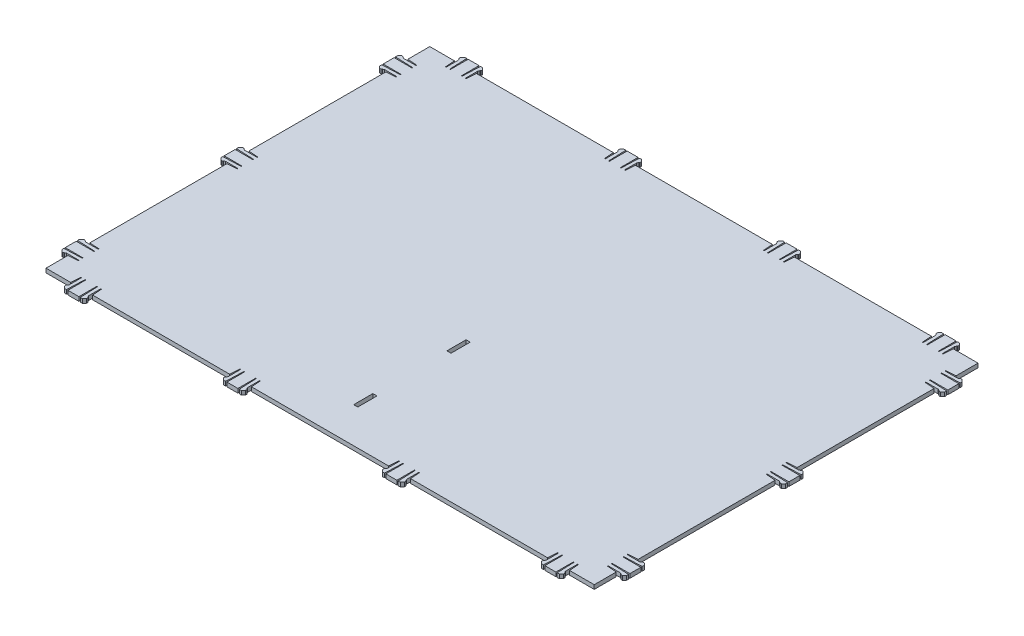
from build123d import *

# Parameters (mm, degrees)
BOSS_EXTRUDE1_DEPTH = 3
SKETCH6_W           = 3
SKETCH6_H           = 14
CUT_EXTRUDE1_DEPTH  = 3


with BuildPart() as part:
    # Sketch1 → Boss-Extrude1 (new body)
    with BuildSketch(Plane(origin=(0, 0, 0), x_dir=(1, 0, 0), z_dir=(0, 1, 0))):
        Polygon((200, 140), (182, 140), (181.5, 132.997828908), (181, 132.997828908), (181, 141.997828908), (181.5, 142.997828908), (182, 143.497828908), (182, 144.497828908), (180.5, 145.997828908), (179, 145.997828908), (178.5, 132.997828908), (178, 132.997828908), (178, 145.997828908), (170, 145.997828908), (170, 132.997828908), (169.5, 132.997828908), (169, 145.997828908), (167.5, 145.997828908), (166, 144.497828908), (166, 143.497828908), (166.5, 142.997828908), (167, 141.997828908), (167, 132.997828908), (166.5, 132.997828908), (166, 140), (66, 140), (65.5, 132.997828908), (65, 132.997828908), (65, 141.997828908), (65.5, 142.997828908), (66, 143.497828908), (66, 144.497828908), (64.5, 145.997828908), (63, 145.997828908), (62.5, 132.997828908), (62, 132.997828908), (62, 145.997828908), (54, 145.997828908), (54, 132.997828908), (53.5, 132.997828908), (53, 145.997828908), (51.5, 145.997828908), (50, 144.497828908), (50, 143.497828908), (50.5, 142.997828908), (51, 141.997828908), (51, 132.997828908), (50.5, 132.997828908), (50, 140), (-50, 140), (-50.5, 132.997828908), (-51, 132.997828908), (-51, 141.997828908), (-50.5, 142.997828908), (-50, 143.497828908), (-50, 144.497828908), (-51.5, 145.997828908), (-53, 145.997828908), (-53.5, 132.997828908), (-54, 132.997828908), (-54, 145.997828908), (-62, 145.997828908), (-62, 132.997828908), (-62.5, 132.997828908), (-63, 145.997828908), (-64.5, 145.997828908), (-66, 144.497828908), (-66, 143.497828908), (-65.5, 142.997828908), (-65, 141.997828908), (-65, 132.997828908), (-65.5, 132.997828908), (-66, 140), (-166, 140), (-166.5, 132.997828908), (-167, 132.997828908), (-167, 141.997828908), (-166.5, 142.997828908), (-166, 143.497828908), (-166, 144.497828908), (-167.5, 145.997828908), (-169, 145.997828908), (-169.5, 132.997828908), (-170, 132.997828908), (-170, 145.997828908), (-178, 145.997828908), (-178, 132.997828908), (-178.5, 132.997828908), (-179, 145.997828908), (-180.5, 145.997828908), (-182, 144.497828908), (-182, 143.497828908), (-181.5, 142.997828908), (-181, 141.997828908), (-181, 132.997828908), (-181.5, 132.997828908), (-182, 140), (-200, 140), (-200, 124), (-192.997828908, 123.5), (-192.997828908, 123), (-201.997828908, 123), (-202.997828908, 123.5), (-203.497828908, 124), (-204.497828908, 124), (-205.997828908, 122.5), (-205.997828908, 121), (-192.997828908, 120.5), (-192.997828908, 120), (-205.997828908, 120), (-205.997828908, 112), (-192.997828908, 112), (-192.997828908, 111.5), (-205.997828908, 111), (-205.997828908, 109.5), (-204.497828908, 108), (-203.497828908, 108), (-202.997828908, 108.5), (-201.997828908, 109), (-192.997828908, 109), (-192.997828908, 108.5), (-200, 108), (-200, 8), (-192.997828908, 7.5), (-192.997828908, 7), (-201.997828908, 7), (-202.997828908, 7.5), (-203.497828908, 8), (-204.497828908, 8), (-205.997828908, 6.5), (-205.997828908, 5), (-192.997828908, 4.5), (-192.997828908, 4), (-205.997828908, 4), (-205.997828908, -4), (-192.997828908, -4), (-192.997828908, -4.5), (-205.997828908, -5), (-205.997828908, -6.5), (-204.497828908, -8), (-203.497828908, -8), (-202.997828908, -7.5), (-201.997828908, -7), (-192.997828908, -7), (-192.997828908, -7.5), (-200, -8), (-200, -108), (-192.997828908, -108.5), (-192.997828908, -109), (-201.997828908, -109), (-202.997828908, -108.5), (-203.497828908, -108), (-204.497828908, -108), (-205.997828908, -109.5), (-205.997828908, -111), (-192.997828908, -111.5), (-192.997828908, -112), (-205.997828908, -112), (-205.997828908, -120), (-192.997828908, -120), (-192.997828908, -120.5), (-205.997828908, -121), (-205.997828908, -122.5), (-204.497828908, -124), (-203.497828908, -124), (-202.997828908, -123.5), (-201.997828908, -123), (-192.997828908, -123), (-192.997828908, -123.5), (-200, -124), (-200, -140), (-182, -140), (-181.5, -132.997828908), (-181, -132.997828908), (-181, -141.997828908), (-181.5, -142.997828908), (-182, -143.497828908), (-182, -144.497828908), (-180.5, -145.997828908), (-179, -145.997828908), (-178.5, -132.997828908), (-178, -132.997828908), (-178, -145.997828908), (-170, -145.997828908), (-170, -132.997828908), (-169.5, -132.997828908), (-169, -145.997828908), (-167.5, -145.997828908), (-166, -144.497828908), (-166, -143.497828908), (-166.5, -142.997828908), (-167, -141.997828908), (-167, -132.997828908), (-166.5, -132.997828908), (-166, -140), (-66, -140), (-65.5, -132.997828908), (-65, -132.997828908), (-65, -141.997828908), (-65.5, -142.997828908), (-66, -143.497828908), (-66, -144.497828908), (-64.5, -145.997828908), (-63, -145.997828908), (-62.5, -132.997828908), (-62, -132.997828908), (-62, -145.997828908), (-54, -145.997828908), (-54, -132.997828908), (-53.5, -132.997828908), (-53, -145.997828908), (-51.5, -145.997828908), (-50, -144.497828908), (-50, -143.497828908), (-50.5, -142.997828908), (-51, -141.997828908), (-51, -132.997828908), (-50.5, -132.997828908), (-50, -140), (50, -140), (50.5, -132.997828908), (51, -132.997828908), (51, -141.997828908), (50.5, -142.997828908), (50, -143.497828908), (50, -144.497828908), (51.5, -145.997828908), (53, -145.997828908), (53.5, -132.997828908), (54, -132.997828908), (54, -145.997828908), (62, -145.997828908), (62, -132.997828908), (62.5, -132.997828908), (63, -145.997828908), (64.5, -145.997828908), (66, -144.497828908), (66, -143.497828908), (65.5, -142.997828908), (65, -141.997828908), (65, -132.997828908), (65.5, -132.997828908), (66, -140), (166, -140), (166.5, -132.997828908), (167, -132.997828908), (167, -141.997828908), (166.5, -142.997828908), (166, -143.497828908), (166, -144.497828908), (167.5, -145.997828908), (169, -145.997828908), (169.5, -132.997828908), (170, -132.997828908), (170, -145.997828908), (178, -145.997828908), (178, -132.997828908), (178.5, -132.997828908), (179, -145.997828908), (180.5, -145.997828908), (182, -144.497828908), (182, -143.497828908), (181.5, -142.997828908), (181, -141.997828908), (181, -132.997828908), (181.5, -132.997828908), (182, -140), (200, -140), (200, -124), (192.997828908, -123.5), (192.997828908, -123), (201.997828908, -123), (202.997828908, -123.5), (203.497828908, -124), (204.497828908, -124), (205.997828908, -122.5), (205.997828908, -121), (192.997828908, -120.5), (192.997828908, -120), (205.997828908, -120), (205.997828908, -112), (192.997828908, -112), (192.997828908, -111.5), (205.997828908, -111), (205.997828908, -109.5), (204.497828908, -108), (203.497828908, -108), (202.997828908, -108.5), (201.997828908, -109), (192.997828908, -109), (192.997828908, -108.5), (200, -108), (200, -8), (192.997828908, -7.5), (192.997828908, -7), (201.997828908, -7), (202.997828908, -7.5), (203.497828908, -8), (204.497828908, -8), (205.997828908, -6.5), (205.997828908, -5), (192.997828908, -4.5), (192.997828908, -4), (205.997828908, -4), (205.997828908, 4), (192.997828908, 4), (192.997828908, 4.5), (205.997828908, 5), (205.997828908, 6.5), (204.497828908, 8), (203.497828908, 8), (202.997828908, 7.5), (201.997828908, 7), (192.997828908, 7), (192.997828908, 7.5), (200, 8), (200, 108), (192.997828908, 108.5), (192.997828908, 109), (201.997828908, 109), (202.997828908, 108.5), (203.497828908, 108), (204.497828908, 108), (205.997828908, 109.5), (205.997828908, 111), (192.997828908, 111.5), (192.997828908, 112), (205.997828908, 112), (205.997828908, 120), (192.997828908, 120), (192.997828908, 120.5), (205.997828908, 121), (205.997828908, 122.5), (204.497828908, 124), (203.497828908, 124), (202.997828908, 123.5), (201.997828908, 123), (192.997828908, 123), (192.997828908, 123.5), (200, 124), align=None)
    extrude(amount=BOSS_EXTRUDE1_DEPTH)

    # Sketch6 → Cut-Extrude1 (cut)
    with BuildSketch(Plane(origin=(0, 3, 0), x_dir=(1, 0, 0), z_dir=(0, 1, 0))):
        with Locations((0, -107)):
            Rectangle(SKETCH6_W, SKETCH6_H)
        with Locations((0, -39)):
            Rectangle(SKETCH6_W, SKETCH6_H)
    extrude(amount=-CUT_EXTRUDE1_DEPTH, mode=Mode.SUBTRACT)


solid = part.part
